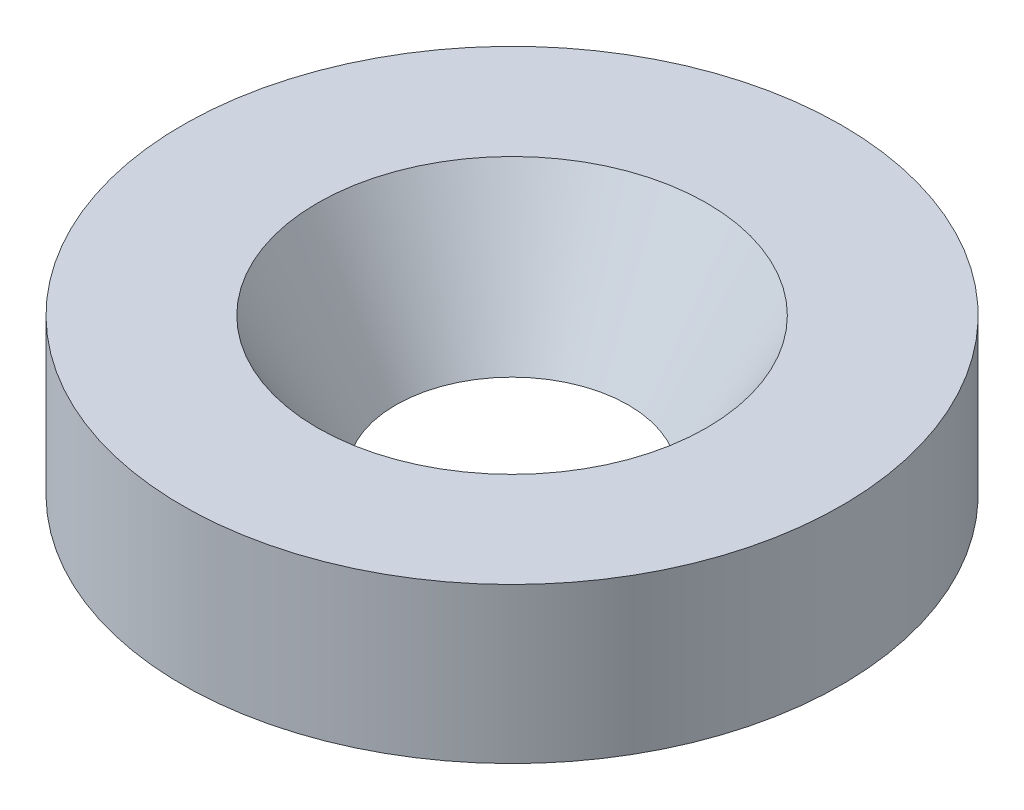
from build123d import *


with BuildPart() as part:
    # Sketch1 → Revolve1 (revolve)
    with BuildSketch(Plane(origin=(0, 0, 0), x_dir=(0, 0, -1), z_dir=(1, 0, 0))):
        Polygon((8, 0), (8.5, 0), (8.5, 4), (5.020725942, 4), (3, 0.5), (6, 0.5), (6, 2.75), (8, 2.75), align=None)
    revolve(axis=Axis((0, 0, 0), (0, 1, 0)))


solid = part.part
